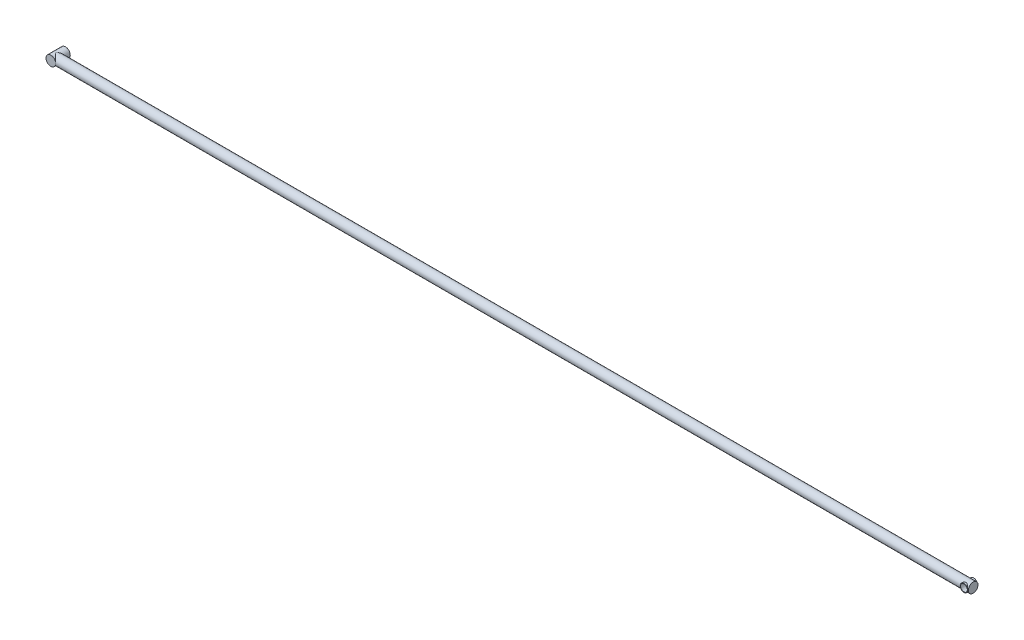
from build123d import *

# Parameters (mm, degrees)
SKETCH_1_R          = 1
EXTRUDE_1_DEPTH     = 3
SKETCH_2_R          = 1
EXTRUDE_2_DEPTH     = 189
SKETCH_3_R          = 0.8
EXTRUDE_3_DEPTH     = 2
SKETCH_4_R          = 0.7
CUT_EXTRUDE_1_DEPTH = 4


with BuildPart() as part:
    # 草图1 → 凸台-拉伸1 (new body)
    with BuildSketch(Plane.XY):
        Circle(SKETCH_1_R)
    extrude(amount=-EXTRUDE_1_DEPTH)

    # 草图2 → 凸台-拉伸2 (add)
    with BuildSketch(Plane(origin=(0, 0, 0), x_dir=(0, 0, -1), z_dir=(1, 0, 0))):
        with Locations((1, 0)):
            Circle(SKETCH_2_R)
    extrude(amount=EXTRUDE_2_DEPTH)

    # 草图3 → 凸台-拉伸3 (add)
    with BuildSketch(Plane.XY):
        with Locations((188.1, 0)):
            Circle(SKETCH_3_R)
    extrude(amount=-EXTRUDE_3_DEPTH)

    # 草图4 → 切除-拉伸1 (cut, through all)
    with BuildSketch(Plane.XY):
        with Locations((188.1, 0)):
            Circle(SKETCH_4_R)
    extrude(amount=-CUT_EXTRUDE_1_DEPTH, mode=Mode.SUBTRACT)


solid = part.part
